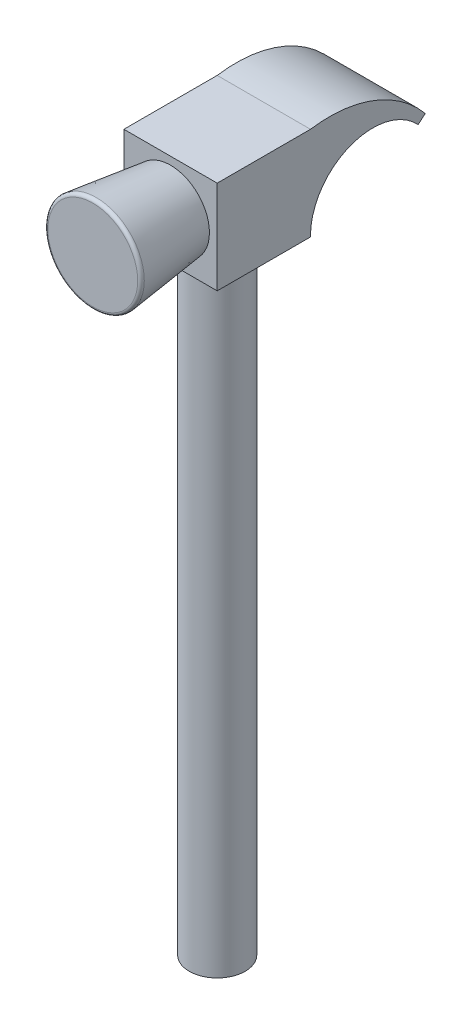
from build123d import *

# Parameters (mm, degrees)
SKETCH1_R                = 9
BOSS_EXTRUDE1_DEPTH      = 200
SKETCH2_W                = 30
SKETCH2_H                = 30
BOSS_EXTRUDE2_DEPTH      = 30
SKETCH6_R                = 12.5
BOSS_EXTRUDE3_DEPTH      = 25
BOSS_EXTRUDE3_DRAFT      = -7
BOSS_EXTRUDE4_DEPTH      = 15
BOSS_EXTRUDE4_DEPTH_BACK = 15
FILLET1_R                = 1


with BuildPart() as part:
    # Sketch1 → Boss-Extrude1 (new body)
    with BuildSketch(Plane(origin=(0, 0, 0), x_dir=(1, 0, 0), z_dir=(0, 1, 0))):
        with Locations(Location((0, 0, 0), (0, 0, 270))):  # turned: the seam where the file's is
            Circle(SKETCH1_R)
    extrude(amount=BOSS_EXTRUDE1_DEPTH)

    # Sketch2 → Boss-Extrude2 (add)
    with BuildSketch(Plane(origin=(0, 200, 0), x_dir=(1, 0, 0), z_dir=(0, 1, 0))):
        Rectangle(SKETCH2_W, SKETCH2_H)
    extrude(amount=BOSS_EXTRUDE2_DEPTH)


with BuildPart() as boss_extrude3_tool:
    # Sketch6 → Boss-Extrude3 (with draft: the straight prism first)
    with BuildSketch(Plane.XY.offset(15)):
        with Locations((0, 215)):
            Circle(SKETCH6_R)
    extrude(amount=BOSS_EXTRUDE3_DEPTH)
    # Boss-Extrude3: the draft: its side faces are tilted about the plane it starts from
    boss_extrude3_sides = [boss_extrude3_tool.faces().sort_by_distance(p)[0] for p in [
        (-12.5, 215, 27.5),
    ]]
    draft(boss_extrude3_sides, Plane.XY.offset(15), BOSS_EXTRUDE3_DRAFT)


with BuildPart() as part_1:
    add(part.part)

    # Boss-Extrude3: add boss_extrude3_tool
    add(boss_extrude3_tool.part)

    # Sketch11 → Boss-Extrude4 (add, two sides)
    with BuildSketch(Plane(origin=(0, 0, 0), x_dir=(0, 0, -1), z_dir=(1, 0, 0))) as boss_extrude4_sk:
        with BuildLine():
            Line((49.61858563, 214.004396393), (51.916718959, 215.932759222))
            ThreePointArc((51.916718959, 215.932759222), (35.317556431, 227.845477966), (15, 230))
            Line((15, 230), (15, 200.717559848))
            ThreePointArc((15, 200.717559848), (27.830359778, 219.030748148), (49.61858563, 214.004396393))
        make_face()
    extrude(amount=BOSS_EXTRUDE4_DEPTH)
    extrude(boss_extrude4_sk.sketch, amount=-BOSS_EXTRUDE4_DEPTH_BACK)

    # Fillet1
    fillet1_edges = [part_1.edges().sort_by_distance(p)[0] for p in [
        (-15.569614023, 215, 40),
    ]]
    fillet(fillet1_edges, radius=FILLET1_R)


solid = part_1.part
